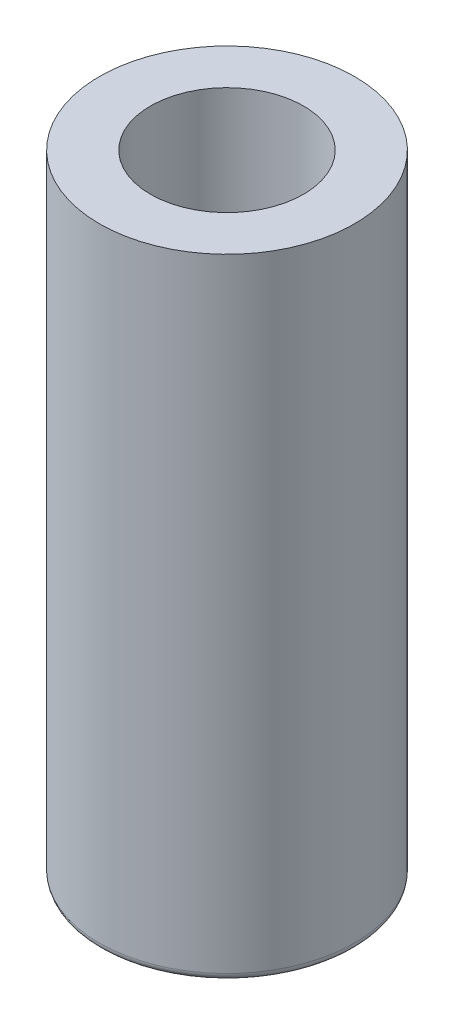
from build123d import *

# Parameters (mm, degrees)
SKETCH1_R           = 8.5
BOSS_EXTRUDE1_DEPTH = 42
FILLET1_R           = 0.5


with BuildPart() as part:
    # Sketch1 → Boss-Extrude1 (new body)
    with BuildSketch(Plane(origin=(0, 0, 0), x_dir=(1, 0, 0), z_dir=(0, 1, 0))):
        Circle(SKETCH1_R)
    extrude(amount=BOSS_EXTRUDE1_DEPTH)

    # Sketch2 → M12 Tapped Hole1 (revolve, cut)
    with BuildSketch(Plane(origin=(0, 42, 0), x_dir=(0, 0, 1), z_dir=(1, 0, 0))):
        Polygon((0, 0), (0, 30.064389157), (5.1, 27), (5.1, 0), align=None)
    revolve(axis=Axis((0, 48.35, 0), (0, -1, 0)), mode=Mode.SUBTRACT)

    # Fillet1
    fillet1_edges = [part.edges().sort_by_distance(p)[0] for p in [
        (-8.5, 0, 0),
    ]]
    fillet(fillet1_edges, radius=FILLET1_R)


solid = part.part
